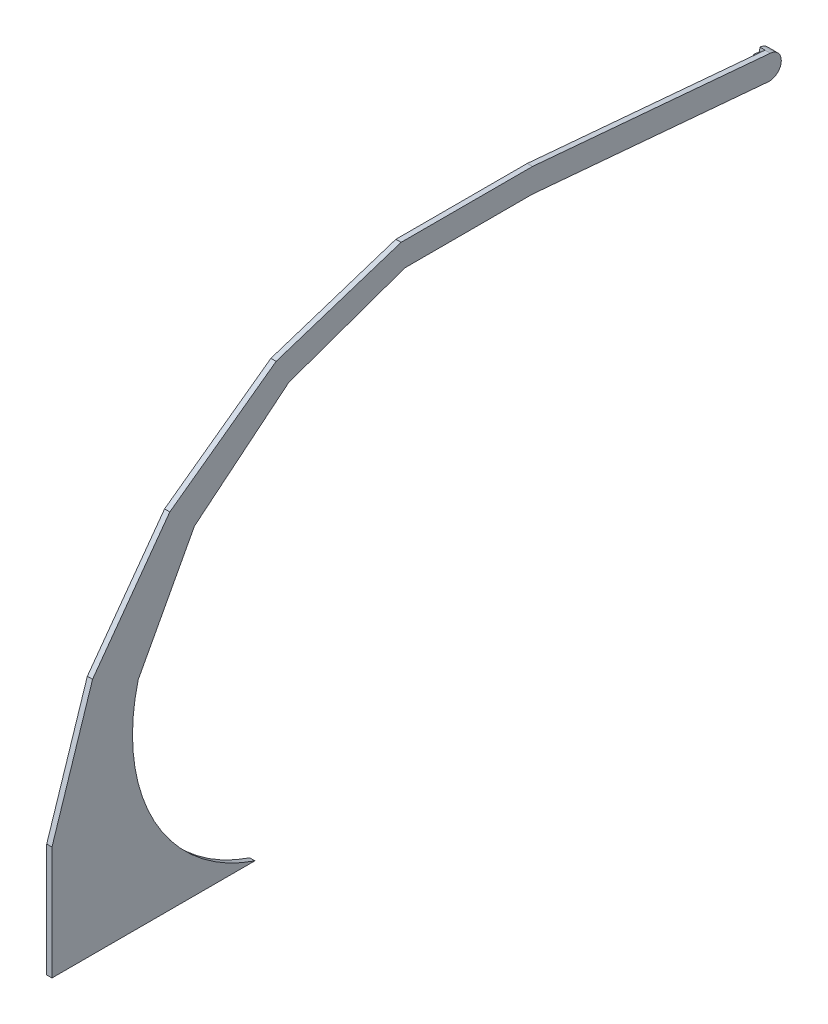
from build123d import *

# Parameters (mm, degrees)
BOSS_EXTRUDE1_DEPTH = 4.4
BOSS_EXTRUDE2_DEPTH = 4.4


with BuildPart() as part:
    # Sketch1 → Boss-Extrude1 (new body)
    with BuildSketch(Plane(origin=(0, 0, 0), x_dir=(0, 0, -1), z_dir=(1, 0, 0))):
        with BuildLine():
            Line((12.615293263, -92.633282396), (182.615293263, -92.633282396))
            ThreePointArc((182.615293263, -92.633282396), (98.271459614, -21.762843967), (84.825943994, 87.579368501))
            Line((84.825943994, 87.579368501), (131.929787104, 175.483372313))
            Line((131.929787104, 175.483372313), (210.884858569, 240.150484061))
            Line((210.884858569, 240.150484061), (308.236471933, 274.689971372))
            Line((308.236471933, 274.689971372), (415.1194685, 274.721469403))
            Line((415.1194685, 274.721469403), (612.615293263, 257.442823643))
            ThreePointArc((612.615293263, 257.442823643), (623.448797672, 266.533213196), (614.358408118, 277.366717604))
            Line((614.358408118, 277.366717604), (415.1194685, 294.797866154))
            Line((415.1194685, 294.797866154), (305.051694272, 294.797866154))
            Line((305.051694272, 294.797866154), (200.371020359, 260.785053385))
            Line((200.371020359, 260.785053385), (111.324320476, 196.088838941))
            Line((111.324320476, 196.088838941), (46.628106033, 107.042139058))
            Line((46.628106033, 107.042139058), (12.615293263, 2.361465145))
            Line((12.615293263, 2.361465145), (12.615293263, -92.633282396))
        make_face()
    extrude(amount=-BOSS_EXTRUDE1_DEPTH)

    # Sketch2 → Boss-Extrude2 (add)
    with BuildSketch(Plane.ZY.offset(4.4)):
        with BuildLine():
            Line((-614.358408118, 277.366717604), (-614.079509741, 274.178894571))
            Line((-614.079509741, 274.178894571), (-609.098536251, 274.614673284))
            Line((-609.098536251, 274.614673284), (-607.91321815, 261.06642539))
            Line((-607.91321815, 261.06642539), (-612.89419164, 260.630646676))
            Line((-612.89419164, 260.630646676), (-612.615293263, 257.442823643))
            ThreePointArc((-612.615293263, 257.442823643), (-623.448797672, 266.533213196), (-614.358408118, 277.366717604))
        make_face()
    extrude(amount=BOSS_EXTRUDE2_DEPTH)


solid = part.part
